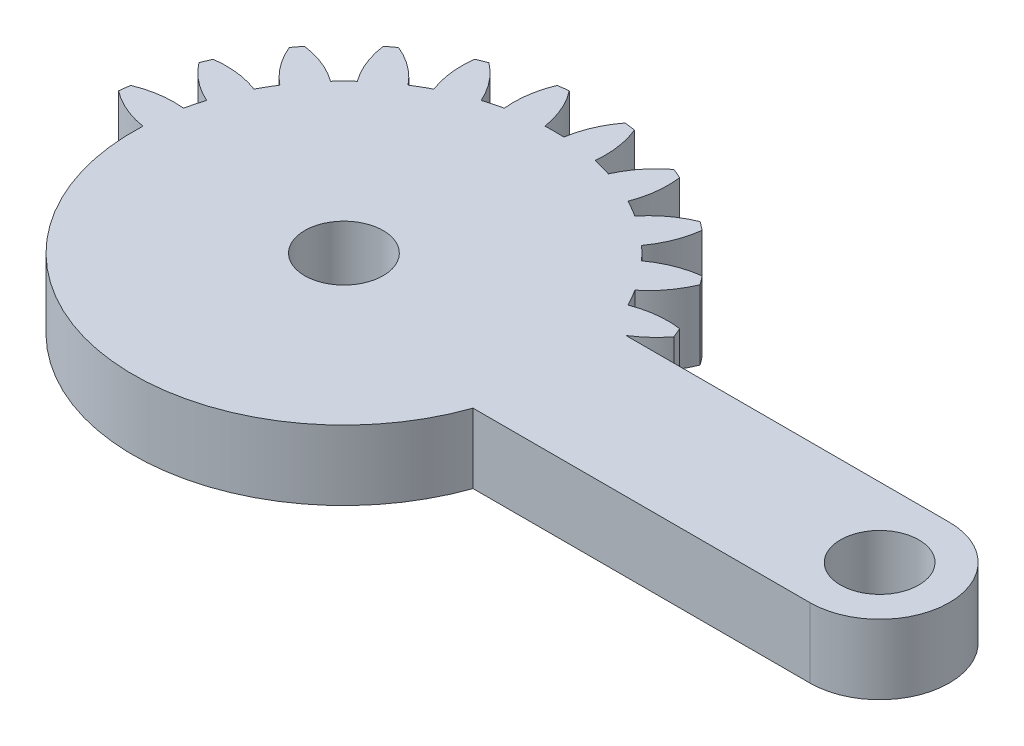
from build123d import *

# Parameters (mm, degrees)
SKETCH1_R           = 2.25
BOSS_EXTRUDE1_DEPTH = 4
CUT_EXTRUDE1_DEPTH  = 10


with BuildPart() as part:
    # Sketch1 → Boss-Extrude1 (new body)
    with BuildSketch(Plane(origin=(0, 0, 0), x_dir=(1, 0, 0), z_dir=(0, 1, 0))):
        with BuildLine():
            Line((20.643657446, 4), (2.081641936, 4))
            ThreePointArc((2.081641936, 4), (2.861028333, 4.588201733), (3.521749436, 5.30713988))
            ThreePointArc((3.521749436, 5.30713988), (3.405395609, 5.596745198), (3.282888305, 5.883801663))
            ThreePointArc((3.282888305, 5.883801663), (1.93527598, 5.894040025), (0.627094961, 5.57027124))
            ThreePointArc((0.627094961, 5.57027124), (0.366286148, 6.046375), (0.084372603, 6.510293938))
            ThreePointArc((0.084372603, 6.510293938), (1.018855105, 7.48132754), (1.683794586, 8.65351323))
            ThreePointArc((1.683794586, 8.65351323), (1.496450048, 8.903135899), (1.303821399, 9.148703928))
            ThreePointArc((1.303821399, 9.148703928), (-0.000522033, 8.809805691), (-1.180330337, 8.158486898))
            ThreePointArc((-1.180330337, 8.158486898), (-1.555477026, 8.550865528), (-1.947855656, 8.926012217))
            ThreePointArc((-1.947855656, 8.926012217), (-1.296536862, 10.105820521), (-0.957638625, 11.410163953))
            ThreePointArc((-0.957638625, 11.410163953), (-1.203206655, 11.602792602), (-1.452829324, 11.79013714))
            ThreePointArc((-1.452829324, 11.79013714), (-2.625015014, 11.125197659), (-3.596048616, 10.190715157))
            ThreePointArc((-3.596048616, 10.190715157), (-4.059967554, 10.472628702), (-4.536071314, 10.733437515))
            ThreePointArc((-4.536071314, 10.733437515), (-4.212302529, 12.041618533), (-4.222540891, 13.389230859))
            ThreePointArc((-4.222540891, 13.389230859), (-4.509597355, 13.511738163), (-4.799202674, 13.62809199))
            ThreePointArc((-4.799202674, 13.62809199), (-5.759348103, 12.682425791), (-6.455432668, 11.528463019))
            ThreePointArc((-6.455432668, 11.528463019), (-6.976508546, 11.680699536), (-7.503891752, 11.809396783))
            ThreePointArc((-7.503891752, 11.809396783), (-7.529737283, 13.156800143), (-7.888414517, 14.455843809))
            ThreePointArc((-7.888414517, 14.455843809), (-8.197396993, 14.499881098), (-8.507248835, 14.537314892))
            ThreePointArc((-8.507248835, 14.537314892), (-9.18992168, 13.375367565), (-9.563620196, 12.080565177))
            ThreePointArc((-9.563620196, 12.080565177), (-10.106342554, 12.09275), (-10.649064912, 12.080565177))
            ThreePointArc((-10.649064912, 12.080565177), (-11.022763428, 13.375367565), (-11.705436272, 14.537314892))
            ThreePointArc((-11.705436272, 14.537314892), (-12.015288115, 14.499881098), (-12.324270591, 14.455843809))
            ThreePointArc((-12.324270591, 14.455843809), (-12.682947825, 13.156800143), (-12.708793355, 11.809396783))
            ThreePointArc((-12.708793355, 11.809396783), (-13.236176561, 11.680699536), (-13.757252439, 11.528463019))
            ThreePointArc((-13.757252439, 11.528463019), (-14.453337005, 12.682425791), (-15.413482434, 13.62809199))
            ThreePointArc((-15.413482434, 13.62809199), (-15.703087752, 13.511738163), (-15.990144217, 13.389230859))
            ThreePointArc((-15.990144217, 13.389230859), (-16.000382579, 12.041618533), (-15.676613793, 10.733437515))
            ThreePointArc((-15.676613793, 10.733437515), (-16.152717554, 10.472628702), (-16.616636492, 10.190715157))
            ThreePointArc((-16.616636492, 10.190715157), (-17.587670094, 11.125197659), (-18.759855783, 11.79013714))
            ThreePointArc((-18.759855783, 11.79013714), (-19.009478453, 11.602792602), (-19.255046482, 11.410163953))
            ThreePointArc((-19.255046482, 11.410163953), (-18.916148245, 10.105820521), (-18.264829452, 8.926012217))
            ThreePointArc((-18.264829452, 8.926012217), (-18.657208082, 8.550865528), (-19.032354771, 8.158486898))
            ThreePointArc((-19.032354771, 8.158486898), (-20.212163074, 8.809805691), (-21.516506507, 9.148703928))
            ThreePointArc((-21.516506507, 9.148703928), (-21.709135156, 8.903135899), (-21.896479694, 8.65351323))
            ThreePointArc((-21.896479694, 8.65351323), (-21.231540213, 7.48132754), (-20.297057711, 6.510293938))
            ThreePointArc((-20.297057711, 6.510293938), (-20.578971255, 6.046375), (-20.839780068, 5.57027124))
            ThreePointArc((-20.839780068, 5.57027124), (-22.147961087, 5.894040025), (-23.495573413, 5.883801663))
            ThreePointArc((-23.495573413, 5.883801663), (-23.618080717, 5.596745198), (-23.734434544, 5.30713988))
            ThreePointArc((-23.734434544, 5.30713988), (-22.788768345, 4.346994451), (-21.634805572, 3.650909885))
            ThreePointArc((-21.634805572, 3.650909885), (-21.78704209, 3.129834008), (-21.915739337, 2.602450802))
            ThreePointArc((-21.915739337, 2.602450802), (-23.263142697, 2.576605271), (-24.562186363, 2.217928037))
            ThreePointArc((-24.562186363, 2.217928037), (-24.606223651, 1.908945561), (-24.643657446, 1.599093719))
            ThreePointArc((-24.643657446, 1.599093719), (-23.481710119, 0.916420874), (-22.186907731, 0.542722358))
            ThreePointArc((-22.186907731, 0.542722358), (-22.199092554, 0), (-22.186907731, -0.542722358))
            ThreePointArc((-22.186907731, -0.542722358), (-23.481710119, -0.916420874), (-24.643657446, -1.599093719))
            ThreePointArc((-24.643657446, -1.599093719), (-24.606223651, -1.908945561), (-24.562186363, -2.217928037))
            ThreePointArc((-24.562186363, -2.217928037), (-23.263142697, -2.576605271), (-21.915739337, -2.602450802))
            ThreePointArc((-21.915739337, -2.602450802), (-21.78704209, -3.129834008), (-21.634805572, -3.650909885))
            ThreePointArc((-21.634805572, -3.650909885), (-22.788768345, -4.346994451), (-23.734434544, -5.30713988))
            ThreePointArc((-23.734434544, -5.30713988), (-23.618080717, -5.596745198), (-23.495573413, -5.883801663))
            ThreePointArc((-23.495573413, -5.883801663), (-22.147961087, -5.894040025), (-20.839780068, -5.57027124))
            ThreePointArc((-20.839780068, -5.57027124), (-20.578971255, -6.046375), (-20.297057711, -6.510293938))
            ThreePointArc((-20.297057711, -6.510293938), (-21.231540213, -7.48132754), (-21.896479694, -8.65351323))
            ThreePointArc((-21.896479694, -8.65351323), (-21.709135156, -8.903135899), (-21.516506507, -9.148703928))
            ThreePointArc((-21.516506507, -9.148703928), (-20.212163074, -8.809805691), (-19.032354771, -8.158486898))
            ThreePointArc((-19.032354771, -8.158486898), (-18.657208082, -8.550865528), (-18.264829452, -8.926012217))
            ThreePointArc((-18.264829452, -8.926012217), (-18.916148245, -10.105820521), (-19.255046482, -11.410163953))
            ThreePointArc((-19.255046482, -11.410163953), (-19.009478453, -11.602792602), (-18.759855783, -11.79013714))
            ThreePointArc((-18.759855783, -11.79013714), (-17.587670094, -11.125197659), (-16.616636492, -10.190715157))
            ThreePointArc((-16.616636492, -10.190715157), (-16.152717554, -10.472628702), (-15.676613793, -10.733437515))
            ThreePointArc((-15.676613793, -10.733437515), (-16.000382579, -12.041618533), (-15.990144217, -13.389230859))
            ThreePointArc((-15.990144217, -13.389230859), (-15.703087752, -13.511738163), (-15.413482434, -13.62809199))
            ThreePointArc((-15.413482434, -13.62809199), (-14.453337005, -12.682425791), (-13.757252439, -11.528463019))
            ThreePointArc((-13.757252439, -11.528463019), (-13.236176561, -11.680699536), (-12.708793355, -11.809396783))
            ThreePointArc((-12.708793355, -11.809396783), (-12.682947825, -13.156800143), (-12.324270591, -14.455843809))
            ThreePointArc((-12.324270591, -14.455843809), (-12.015288115, -14.499881098), (-11.705436272, -14.537314892))
            ThreePointArc((-11.705436272, -14.537314892), (-11.022763428, -13.375367565), (-10.649064912, -12.080565177))
            ThreePointArc((-10.649064912, -12.080565177), (-10.106342554, -12.09275), (-9.563620196, -12.080565177))
            ThreePointArc((-9.563620196, -12.080565177), (-9.18992168, -13.375367565), (-8.507248835, -14.537314892))
            ThreePointArc((-8.507248835, -14.537314892), (-8.197396993, -14.499881098), (-7.888414517, -14.455843809))
            ThreePointArc((-7.888414517, -14.455843809), (-7.529737283, -13.156800143), (-7.503891752, -11.809396783))
            ThreePointArc((-7.503891752, -11.809396783), (-6.976508546, -11.680699536), (-6.455432668, -11.528463019))
            ThreePointArc((-6.455432668, -11.528463019), (-5.759348103, -12.682425791), (-4.799202674, -13.62809199))
            ThreePointArc((-4.799202674, -13.62809199), (-4.509597355, -13.511738163), (-4.222540891, -13.389230859))
            ThreePointArc((-4.222540891, -13.389230859), (-4.212302529, -12.041618533), (-4.536071314, -10.733437515))
            ThreePointArc((-4.536071314, -10.733437515), (-4.059967554, -10.472628702), (-3.596048616, -10.190715157))
            ThreePointArc((-3.596048616, -10.190715157), (-2.625015014, -11.125197659), (-1.452829324, -11.79013714))
            ThreePointArc((-1.452829324, -11.79013714), (-1.203206655, -11.602792602), (-0.957638625, -11.410163953))
            ThreePointArc((-0.957638625, -11.410163953), (-1.296536862, -10.105820521), (-1.947855656, -8.926012217))
            ThreePointArc((-1.947855656, -8.926012217), (-1.555477026, -8.550865528), (-1.180330337, -8.158486898))
            ThreePointArc((-1.180330337, -8.158486898), (-0.000522033, -8.809805691), (1.303821399, -9.148703928))
            ThreePointArc((1.303821399, -9.148703928), (1.496450048, -8.903135899), (1.683794586, -8.65351323))
            ThreePointArc((1.683794586, -8.65351323), (1.018855105, -7.48132754), (0.084372603, -6.510293938))
            ThreePointArc((0.084372603, -6.510293938), (0.366286148, -6.046375), (0.627094961, -5.57027124))
            ThreePointArc((0.627094961, -5.57027124), (1.93527598, -5.894040025), (3.282888305, -5.883801663))
            ThreePointArc((3.282888305, -5.883801663), (3.405395609, -5.596745198), (3.521749436, -5.30713988))
            ThreePointArc((3.521749436, -5.30713988), (2.861028333, -4.588201733), (2.081641936, -4))
            Line((2.081641936, -4), (20.643657446, -4))
            ThreePointArc((20.643657446, -4), (24.643657446, 0), (20.643657446, 4))
        make_face()
        with Locations((-10.106342554, 0)):
            Circle(SKETCH1_R, mode=Mode.SUBTRACT)
        with Locations((20.643657446, 0)):
            Circle(SKETCH1_R, mode=Mode.SUBTRACT)
    extrude(amount=BOSS_EXTRUDE1_DEPTH)

    # Sketch2 → Cut-Extrude1 (cut)
    with BuildSketch(Plane(origin=(0, 4, 0), x_dir=(1, 0, 0), z_dir=(0, 1, 0))):
        with BuildLine():
            ThreePointArc((-24.562186363, -2.217928037), (-23.263142697, -2.576605271), (-21.915739337, -2.602450802))
            ThreePointArc((-21.915739337, -2.602450802), (-22.095637401, -1.578420611), (-22.186907731, -0.542722358))
            ThreePointArc((-22.186907731, -0.542722358), (-23.481710119, -0.916420874), (-24.643657446, -1.599093719))
            ThreePointArc((-24.643657446, -1.599093719), (-24.606223651, -1.908945561), (-24.562186363, -2.217928037))
        make_face()
        with BuildLine():
            ThreePointArc((-23.495573413, -5.883801663), (-22.147961087, -5.894040025), (-20.839780068, -5.57027124))
            ThreePointArc((-20.839780068, -5.57027124), (-21.278586771, -4.627695077), (-21.634805572, -3.650909885))
            ThreePointArc((-21.634805572, -3.650909885), (-22.788768345, -4.346994451), (-23.734434544, -5.30713988))
            ThreePointArc((-23.734434544, -5.30713988), (-23.618080717, -5.596745198), (-23.495573413, -5.883801663))
        make_face()
        with BuildLine():
            ThreePointArc((-21.516506507, -9.148703928), (-20.212163074, -8.809805691), (-19.032354771, -8.158486898))
            ThreePointArc((-19.032354771, -8.158486898), (-19.70016616, -7.361599771), (-20.297057711, -6.510293938))
            ThreePointArc((-20.297057711, -6.510293938), (-21.231540213, -7.48132754), (-21.896479694, -8.65351323))
            ThreePointArc((-21.896479694, -8.65351323), (-21.709135156, -8.903135899), (-21.516506507, -9.148703928))
        make_face()
        with BuildLine():
            ThreePointArc((-18.759855783, -11.79013714), (-17.587670094, -11.125197659), (-16.616636492, -10.190715157))
            ThreePointArc((-16.616636492, -10.190715157), (-17.467942324, -9.593823606), (-18.264829452, -8.926012217))
            ThreePointArc((-18.264829452, -8.926012217), (-18.916148245, -10.105820521), (-19.255046482, -11.410163953))
            ThreePointArc((-19.255046482, -11.410163953), (-19.009478453, -11.602792602), (-18.759855783, -11.79013714))
        make_face()
        with BuildLine():
            ThreePointArc((-15.413482434, -13.62809199), (-14.453337005, -12.682425791), (-13.757252439, -11.528463019))
            ThreePointArc((-13.757252439, -11.528463019), (-14.734037631, -11.172244217), (-15.676613793, -10.733437515))
            ThreePointArc((-15.676613793, -10.733437515), (-16.000382579, -12.041618533), (-15.990144217, -13.389230859))
            ThreePointArc((-15.990144217, -13.389230859), (-15.703087752, -13.511738163), (-15.413482434, -13.62809199))
        make_face()
        with BuildLine():
            ThreePointArc((-11.705436272, -14.537314892), (-11.022763428, -13.375367565), (-10.649064912, -12.080565177))
            ThreePointArc((-10.649064912, -12.080565177), (-11.684763165, -11.989294847), (-12.708793355, -11.809396783))
            ThreePointArc((-12.708793355, -11.809396783), (-12.682947825, -13.156800143), (-12.324270591, -14.455843809))
            ThreePointArc((-12.324270591, -14.455843809), (-12.015288115, -14.499881098), (-11.705436272, -14.537314892))
        make_face()
        with BuildLine():
            ThreePointArc((-7.888414517, -14.455843809), (-7.529737283, -13.156800143), (-7.503891752, -11.809396783))
            ThreePointArc((-7.503891752, -11.809396783), (-8.527921943, -11.989294847), (-9.563620196, -12.080565177))
            ThreePointArc((-9.563620196, -12.080565177), (-9.18992168, -13.375367565), (-8.507248835, -14.537314892))
            ThreePointArc((-8.507248835, -14.537314892), (-8.197396993, -14.499881098), (-7.888414517, -14.455843809))
        make_face()
        with BuildLine():
            ThreePointArc((-4.222540891, -13.389230859), (-4.212302529, -12.041618533), (-4.536071314, -10.733437515))
            ThreePointArc((-4.536071314, -10.733437515), (-5.478647477, -11.172244217), (-6.455432668, -11.528463019))
            ThreePointArc((-6.455432668, -11.528463019), (-5.759348103, -12.682425791), (-4.799202674, -13.62809199))
            ThreePointArc((-4.799202674, -13.62809199), (-4.509597355, -13.511738163), (-4.222540891, -13.389230859))
        make_face()
        with BuildLine():
            ThreePointArc((-0.957638625, -11.410163953), (-1.296536862, -10.105820521), (-1.947855656, -8.926012217))
            ThreePointArc((-1.947855656, -8.926012217), (-2.744742783, -9.593823606), (-3.596048616, -10.190715157))
            ThreePointArc((-3.596048616, -10.190715157), (-2.625015014, -11.125197659), (-1.452829324, -11.79013714))
            ThreePointArc((-1.452829324, -11.79013714), (-1.203206655, -11.602792602), (-0.957638625, -11.410163953))
        make_face()
        with BuildLine():
            ThreePointArc((1.683794586, -8.65351323), (1.018855105, -7.48132754), (0.084372603, -6.510293938))
            ThreePointArc((0.084372603, -6.510293938), (-0.512518948, -7.361599771), (-1.180330337, -8.158486898))
            ThreePointArc((-1.180330337, -8.158486898), (-0.000522033, -8.809805691), (1.303821399, -9.148703928))
            ThreePointArc((1.303821399, -9.148703928), (1.496450048, -8.903135899), (1.683794586, -8.65351323))
        make_face()
        with BuildLine():
            ThreePointArc((3.521749436, -5.30713988), (2.861028333, -4.588201733), (2.081641936, -4))
            Line((2.081641936, -4), (1.305695063, -4))
            ThreePointArc((1.305695063, -4), (0.994195953, -4.797149927), (0.627094961, -5.57027124))
            ThreePointArc((0.627094961, -5.57027124), (1.93527598, -5.894040025), (3.282888305, -5.883801663))
            ThreePointArc((3.282888305, -5.883801663), (3.405395609, -5.596745198), (3.521749436, -5.30713988))
        make_face()
    extrude(amount=-CUT_EXTRUDE1_DEPTH, mode=Mode.SUBTRACT)


solid = part.part
